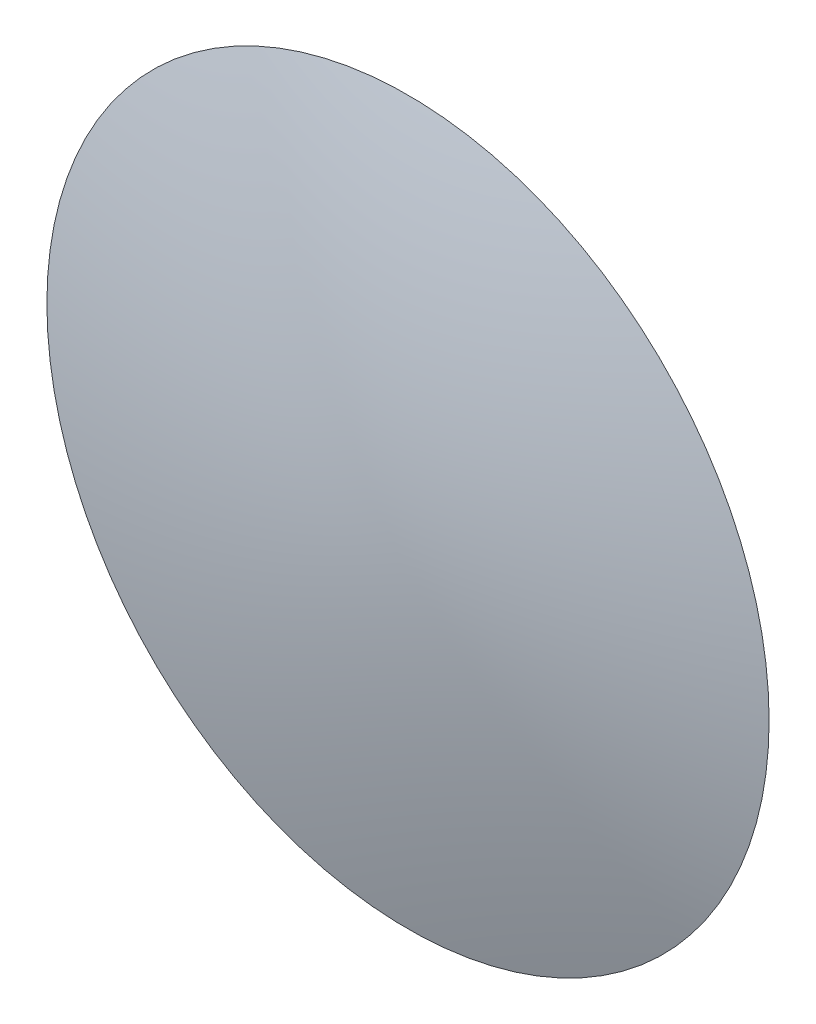
from build123d import *


with BuildPart() as part:
    # 草图3 → 旋转1 (revolve)
    with BuildSketch(Plane(origin=(0, 0, 0), x_dir=(1, 0, 0), z_dir=(0, 1, 0))):
        with BuildLine():
            Line((0, 2.5), (0, -2.5))
            add(Edge.make_bspline(
                [(0, -2.5), (-6.25, -2.5), (-15, 0)],
                knots=[0.5, 0.5, 0.5, 1, 1, 1], degree=2))
            add(Edge.make_bspline(
                [(-15, 0), (-6.25, 2.5), (0, 2.5)],
                knots=[0, 0, 0, 0.5, 0.5, 0.5], degree=2))
        make_face()
    revolve(axis=Axis((0, 0, -2.5), (0, 0, 1)))


solid = part.part
